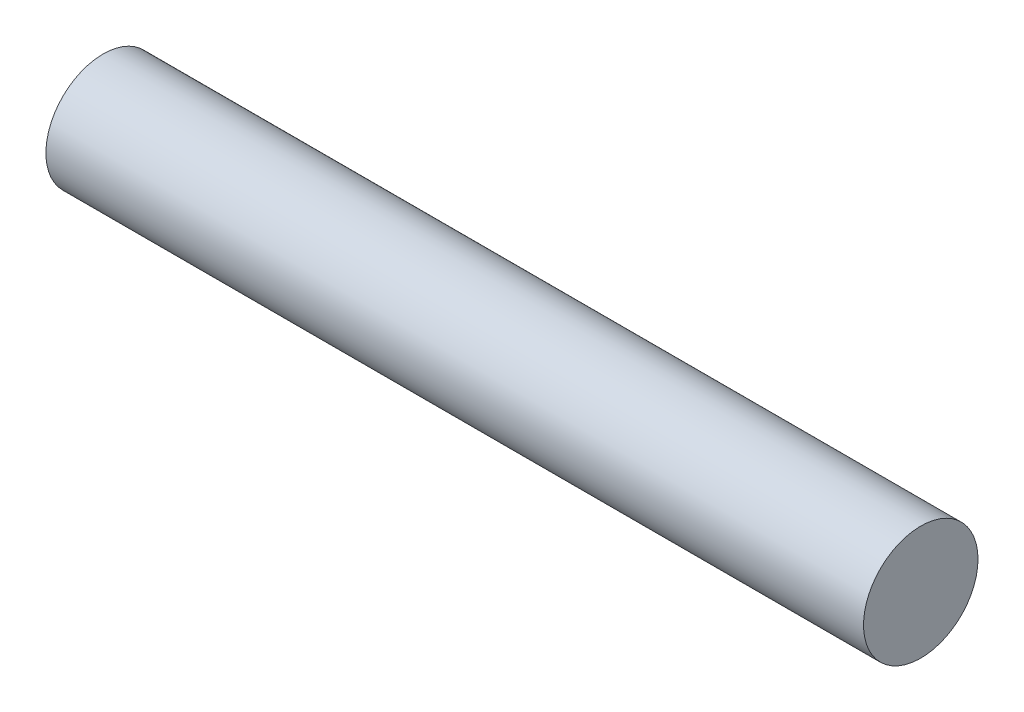
from build123d import *

# Parameters (mm, degrees)
SKETCH1_R           = 11.1125
BOSS_EXTRUDE1_DEPTH = 79.375


with BuildPart() as part:
    # Sketch1 → Boss-Extrude1 (new body, symmetric)
    with BuildSketch(Plane(origin=(0, 0, 0), x_dir=(0, 0, -1), z_dir=(1, 0, 0))):
        Circle(SKETCH1_R)
    extrude(amount=BOSS_EXTRUDE1_DEPTH, both=True)


solid = part.part
